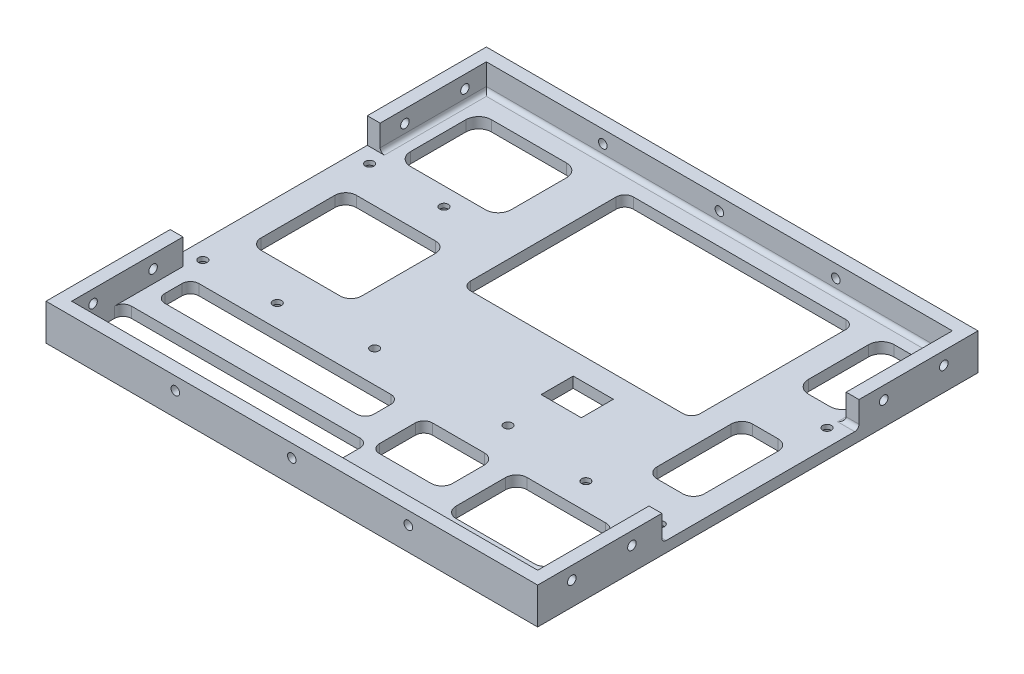
from build123d import *

# Parameters (mm, degrees)
SKETCH1_W           = 119
SKETCH1_H           = 103
BOSS_EXTRUDE1_DEPTH = 2.5
SKETCH3_W           = 55
SKETCH3_H           = 44
CUT_EXTRUDE2_DEPTH  = 10
SKETCH4_W           = 103
SKETCH4_H           = 2.5
BOSS_EXTRUDE2_DEPTH = 1.5
SKETCH5_W           = 103
SKETCH5_H           = 2.5
BOSS_EXTRUDE3_DEPTH = 1.5
SKETCH6_W           = 103
SKETCH6_H           = 2.5
CUT_EXTRUDE3_DEPTH  = 3.5
SKETCH7_W           = 103
SKETCH7_H           = 2.5
CUT_EXTRUDE4_DEPTH  = 3.5
SKETCH8_R           = 1
CUT_EXTRUDE5_DEPTH  = 10
CUT_EXTRUDE9_DEPTH  = 11
SKETCH13_W          = 7.420596405
SKETCH13_H          = 28.066266443
SKETCH13_H_2        = 28.109143465
BOSS_EXTRUDE4_DEPTH = 2.5
BOSS_EXTRUDE5_DEPTH = 5
FILLET1_R           = 1
SKETCH15_R          = 1
CUT_EXTRUDE10_DEPTH = 5
SKETCH16_R          = 1
CUT_EXTRUDE11_DEPTH = 5
BOSS_EXTRUDE6_DEPTH = 1
SKETCH18_R          = 1
CUT_EXTRUDE12_DEPTH = 10
SKETCH19_W          = 10.420596405
SKETCH19_H          = 31.066266443
SKETCH19_H_2        = 31.109143465
SKETCH19_W_2        = 9.39736678
SKETCH19_H_3        = 7.5
CUT_EXTRUDE13_DEPTH = 10
SKETCH20_R          = 2
CUT_EXTRUDE14_DEPTH = 1.5
SKETCH21_W          = 53.725269585
SKETCH21_H          = 38.08766447
CUT_EXTRUDE15_DEPTH = 21.5
FILLET2_R           = 2


with BuildPart() as part:
    # Sketch1 → Boss-Extrude1 (new body)
    with BuildSketch(Plane(origin=(0, 0, 0), x_dir=(1, 0, 0), z_dir=(0, 1, 0))):
        Rectangle(SKETCH1_W, SKETCH1_H)
    extrude(amount=BOSS_EXTRUDE1_DEPTH)

    # Sketch3 → Cut-Extrude2 (cut)
    with BuildSketch(Plane(origin=(0, 2.5, 0), x_dir=(1, 0, 0), z_dir=(0, 1, 0))):
        with Locations((9, 16.5)):
            Rectangle(SKETCH3_W, SKETCH3_H)
    extrude(amount=-CUT_EXTRUDE2_DEPTH, mode=Mode.SUBTRACT)

    # Sketch4 → Boss-Extrude2 (add)
    with BuildSketch(Plane.ZY.offset(59.5)):
        with Locations((0, 1.25)):
            Rectangle(SKETCH4_W, SKETCH4_H)
    extrude(amount=BOSS_EXTRUDE2_DEPTH)

    # Sketch5 → Boss-Extrude3 (add)
    with BuildSketch(Plane(origin=(59.5, 0, 0), x_dir=(0, 0, -1), z_dir=(1, 0, 0))):
        with Locations((0, 1.25)):
            Rectangle(SKETCH5_W, SKETCH5_H)
    extrude(amount=BOSS_EXTRUDE3_DEPTH)

    # Sketch6 → Cut-Extrude3 (cut)
    with BuildSketch(Plane.ZY.offset(61)):
        with Locations((0, 1.25)):
            Rectangle(SKETCH6_W, SKETCH6_H)
    extrude(amount=-CUT_EXTRUDE3_DEPTH, mode=Mode.SUBTRACT)

    # Sketch7 → Cut-Extrude4 (cut)
    with BuildSketch(Plane(origin=(61, 0, 0), x_dir=(0, 0, -1), z_dir=(1, 0, 0))):
        with Locations((0, 1.25)):
            Rectangle(SKETCH7_W, SKETCH7_H)
    extrude(amount=-CUT_EXTRUDE4_DEPTH, mode=Mode.SUBTRACT)

    # Sketch8 → Cut-Extrude5 (cut)
    with BuildSketch(Plane(origin=(0, 2.5, 0), x_dir=(1, 0, 0), z_dir=(0, 1, 0))):
        with Locations((-15.5, -44.96)):
            Circle(SKETCH8_R)
        with Locations((15.7, -44.96)):
            Circle(SKETCH8_R)
        with Locations((-15.5, -16.63)):
            Circle(SKETCH8_R)
        with Locations((15.7, -16.63)):
            Circle(SKETCH8_R)
        with Locations((-53.5, -18.81)):
            Circle(SKETCH8_R)
        with Locations((-36.1, -18.81)):
            Circle(SKETCH8_R)
        with Locations((-53.5, 20.19)):
            Circle(SKETCH8_R)
        with Locations((-36.1, 20.19)):
            Circle(SKETCH8_R)
        with Locations((36.1, -18.81)):
            Circle(SKETCH8_R)
        with Locations((53.5, -18.81)):
            Circle(SKETCH8_R)
        with Locations((53.5, 20.19)):
            Circle(SKETCH8_R)
    extrude(amount=-CUT_EXTRUDE5_DEPTH, mode=Mode.SUBTRACT)

    # Sketch12 → Cut-Extrude9 (cut)
    with BuildSketch(Plane(origin=(0, 2.5, 0), x_dir=(1, 0, 0), z_dir=(0, 1, 0))):
        with BuildLine():
            Line((18.457129996, -37.366758765), (6.341274381, -37.366758765))
            ThreePointArc((6.341274381, -37.366758765), (4.927060818, -36.780972327), (4.341274381, -35.366758765))
            Line((4.341274381, -35.366758765), (4.341274381, -26.945491093))
            ThreePointArc((4.341274381, -26.945491093), (4.927060818, -25.53127753), (6.341274381, -24.945491093))
            Line((6.341274381, -24.945491093), (18.457129996, -24.945491093))
            ThreePointArc((18.457129996, -24.945491093), (20.224896949, -25.67772414), (20.957129996, -27.445491093))
            Line((20.957129996, -27.445491093), (20.957129996, -34.866758765))
            ThreePointArc((20.957129996, -34.866758765), (20.224896949, -36.634525718), (18.457129996, -37.366758765))
        make_face()
        with BuildLine():
            Line((-48.675698452, -10.035902375), (-30.13630944, -10.035902375))
            ThreePointArc((-30.13630944, -10.035902375), (-28.368542487, -9.303669328), (-27.63630944, -7.535902375))
            Line((-27.63630944, -7.535902375), (-27.63630944, 9.759475357))
            ThreePointArc((-27.63630944, 9.759475357), (-28.368542487, 11.52724231), (-30.13630944, 12.259475357))
            Line((-30.13630944, 12.259475357), (-48.675698452, 12.259475357))
            ThreePointArc((-48.675698452, 12.259475357), (-50.443465405, 11.52724231), (-51.175698452, 9.759475357))
            Line((-51.175698452, 9.759475357), (-51.175698452, -7.535902375))
            ThreePointArc((-51.175698452, -7.535902375), (-50.443465405, -9.303669328), (-48.675698452, -10.035902375))
        make_face()
        with BuildLine():
            Line((0.941406426, -48.5), (-52.5, -48.5))
            ThreePointArc((-52.5, -48.5), (-53.914213562, -47.914213562), (-54.5, -46.5))
            Line((-54.5, -46.5), (-54.5, -38.5))
            ThreePointArc((-54.5, -38.5), (-53.914213562, -37.085786438), (-52.5, -36.5))
            Line((-52.5, -36.5), (0.941406426, -36.5))
            ThreePointArc((0.941406426, -36.5), (2.355619989, -37.085786438), (2.941406426, -38.5))
            Line((2.941406426, -38.5), (2.941406426, -46.5))
            ThreePointArc((2.941406426, -46.5), (2.355619989, -47.914213562), (0.941406426, -48.5))
        make_face()
        with BuildLine():
            Line((28.457129996, -41.565269049), (46.850265705, -41.565269049))
            ThreePointArc((46.850265705, -41.565269049), (48.618032658, -40.833036002), (49.350265705, -39.065269049))
            Line((49.350265705, -39.065269049), (49.350265705, -27.445491093))
            ThreePointArc((49.350265705, -27.445491093), (48.618032658, -25.67772414), (46.850265705, -24.945491093))
            Line((46.850265705, -24.945491093), (28.457129996, -24.945491093))
            ThreePointArc((28.457129996, -24.945491093), (26.689363043, -25.67772414), (25.957129996, -27.445491093))
            Line((25.957129996, -27.445491093), (25.957129996, -39.065269049))
            ThreePointArc((25.957129996, -39.065269049), (26.689363043, -40.833036002), (28.457129996, -41.565269049))
        make_face()
        with BuildLine():
            Line((41.5, 9.759475357), (41.5, -7.535902375))
            ThreePointArc((41.5, -7.535902375), (42.232233047, -9.303669328), (44, -10.035902375))
            Line((44, -10.035902375), (50, -10.035902375))
            ThreePointArc((50, -10.035902375), (51.767766953, -9.303669328), (52.5, -7.535902375))
            Line((52.5, -7.535902375), (52.5, 9.759475357))
            ThreePointArc((52.5, 9.759475357), (51.767766953, 11.52724231), (50, 12.259475357))
            Line((50, 12.259475357), (44, 12.259475357))
            ThreePointArc((44, 12.259475357), (42.232233047, 11.52724231), (41.5, 9.759475357))
        make_face()
        with BuildLine():
            Line((-4.277537088, -32.033396205), (-49.175698452, -32.033396205))
            ThreePointArc((-49.175698452, -32.033396205), (-50.589912015, -31.447609768), (-51.175698452, -30.033396205))
            Line((-51.175698452, -30.033396205), (-51.175698452, -26.033396205))
            ThreePointArc((-51.175698452, -26.033396205), (-50.589912015, -24.619182643), (-49.175698452, -24.033396205))
            Line((-49.175698452, -24.033396205), (-4.277537088, -24.033396205))
            ThreePointArc((-4.277537088, -24.033396205), (-2.863323525, -24.619182643), (-2.277537088, -26.033396205))
            Line((-2.277537088, -26.033396205), (-2.277537088, -30.033396205))
            ThreePointArc((-2.277537088, -30.033396205), (-2.863323525, -31.447609768), (-4.277537088, -32.033396205))
        make_face()
        with BuildLine():
            Line((-30.63630944, 24.426024877), (-48.175698452, 24.426024877))
            ThreePointArc((-48.175698452, 24.426024877), (-50.297018796, 25.304704534), (-51.175698452, 27.426024877))
            Line((-51.175698452, 27.426024877), (-51.175698452, 40.3778965))
            ThreePointArc((-51.175698452, 40.3778965), (-50.297018796, 42.499216844), (-48.175698452, 43.3778965))
            Line((-48.175698452, 43.3778965), (-30.63630944, 43.3778965))
            ThreePointArc((-30.63630944, 43.3778965), (-28.514989096, 42.499216844), (-27.63630944, 40.3778965))
            Line((-27.63630944, 40.3778965), (-27.63630944, 27.426024877))
            ThreePointArc((-27.63630944, 27.426024877), (-28.514989096, 25.304704534), (-30.63630944, 24.426024877))
        make_face()
        with BuildLine():
            Line((49.5, 24.845275514), (44.5, 24.845275514))
            ThreePointArc((44.5, 24.845275514), (42.378679656, 25.72395517), (41.5, 27.845275514))
            Line((41.5, 27.845275514), (41.5, 41.894735662))
            ThreePointArc((41.5, 41.894735662), (42.378679656, 44.016056005), (44.5, 44.894735662))
            Line((44.5, 44.894735662), (49.5, 44.894735662))
            ThreePointArc((49.5, 44.894735662), (51.621320344, 44.016056005), (52.5, 41.894735662))
            Line((52.5, 41.894735662), (52.5, 27.845275514))
            ThreePointArc((52.5, 27.845275514), (51.621320344, 25.72395517), (49.5, 24.845275514))
        make_face()
    extrude(amount=-CUT_EXTRUDE9_DEPTH, mode=Mode.SUBTRACT)

    # Sketch13 → Boss-Extrude4 (add)
    with BuildSketch(Plane(origin=(0, 2.5, 0), x_dir=(1, 0, 0), z_dir=(0, 1, 0))):
        Polygon((21.712749583, -5.5), (36.5, -5.5), (36.5, 7.734017607), (36.5, 38.5), (26.428134907, 38.5), (-8.428134907, 38.5), (-18.5, 38.5), (-18.5, 7.734017607), (-18.5, -5.5), (-3.712749583, -5.5), (3.684617197, -5.5), (14.315382803, -5.5), (14.315382803, -0.063611644), (21.712749583, -0.063611644), align=None)
        with Locations((30.567238931, 21.767150829)):
            Rectangle(SKETCH13_W, SKETCH13_H, mode=Mode.SUBTRACT)
        with Locations((-12.567238931, 21.788589339)):
            Rectangle(SKETCH13_W, SKETCH13_H_2, mode=Mode.SUBTRACT)
    extrude(amount=-BOSS_EXTRUDE4_DEPTH)

    # Sketch14 → Boss-Extrude5 (add)
    with BuildSketch(Plane(origin=(0, 2.5, 0), x_dir=(1, 0, 0), z_dir=(0, 1, 0))):
        Polygon((57.5, 23.659080622), (54.5, 23.659080622), (54.5, 48.5), (-54.5, 48.5), (-54.5, 23.659080622), (-57.5, 23.659080622), (-57.5, 51.5), (57.5, 51.5), align=None)
        Polygon((57.5, -22.451645152), (54.5, -22.451645152), (54.5, -48.5), (-54.5, -48.5), (-54.5, -22.451645152), (-57.5, -22.451645152), (-57.5, -51.5), (57.5, -51.5), align=None)
    extrude(amount=BOSS_EXTRUDE5_DEPTH)

    # Fillet1
    fillet1_edges = [part.edges().sort_by_distance(p)[0] for p in [
        (-54.5, 2.5, -36.079540311),
        (0, 2.5, -48.5),
        (54.5, 2.5, -36.079540311),
        (56, 2.5, -23.659080622),
        (56, 2.5, 22.451645152),
        (54.5, 2.5, 35.475822576),
        (27.720703213, 2.5, 48.5),
        (-54.5, 2.5, 47.5),
    ]]
    fillet(fillet1_edges, radius=FILLET1_R)

    # Sketch15 → Cut-Extrude10 (cut)
    with BuildSketch(Plane.ZY.offset(-54.5)):
        with Locations((29.451645152, 5.5)):
            Circle(SKETCH15_R)
        with Locations((43.5, 5.5)):
            Circle(SKETCH15_R)
    cut_extrude10 = extrude(amount=-CUT_EXTRUDE10_DEPTH, mode=Mode.SUBTRACT)

    # Sketch16 → Cut-Extrude11 (cut)
    with BuildSketch(Plane(origin=(0, 0, 48.5), x_dir=(-1, 0, 0), z_dir=(0, 0, -1))):
        with Locations((0, 5.5)):
            Circle(SKETCH16_R)
        with Locations((-27.25, 5.5)):
            Circle(SKETCH16_R)
        with Locations((27.25, 5.5)):
            Circle(SKETCH16_R)
    cut_extrude11 = extrude(amount=-CUT_EXTRUDE11_DEPTH, mode=Mode.SUBTRACT)

    # Sketch17 → Boss-Extrude6 (add)
    with BuildSketch(Plane(origin=(0, 7.5, 0), x_dir=(1, 0, 0), z_dir=(0, 1, 0))):
        Polygon((57.5, -51.5), (57.5, -22.451645152), (54.5, -22.451645152), (54.5, -48.5), (-54.5, -48.5), (-54.5, -22.451645152), (-57.5, -22.451645152), (-57.5, -51.5), align=None)
        Polygon((57.5, 23.659080622), (57.5, 51.5), (-57.5, 51.5), (-57.5, 23.659080622), (-54.5, 23.659080622), (-54.5, 48.5), (54.5, 48.5), (54.5, 23.659080622), align=None)
    extrude(amount=BOSS_EXTRUDE6_DEPTH)

    # Mirror1: Cut-Extrude10, Cut-Extrude11 across plane
    add(cut_extrude10.mirror(Plane.XY), mode=Mode.SUBTRACT)
    add(cut_extrude11.mirror(Plane.XY), mode=Mode.SUBTRACT)

    # Mirror2: Cut-Extrude10 across plane
    add(cut_extrude10.mirror(Plane(origin=(0, 0, 0), x_dir=(0, 0, 1), z_dir=(1, 0, 0))), mode=Mode.SUBTRACT)

    # Sketch18 → Cut-Extrude12 (cut)
    with BuildSketch(Plane(origin=(-54.5, 0, 0), x_dir=(0, 0, -1), z_dir=(1, 0, 0))):
        with Locations((43.5, 5.5)):
            Circle(SKETCH18_R)
        with Locations((29.451645152, 5.5)):
            Circle(SKETCH18_R)
    extrude(amount=-CUT_EXTRUDE12_DEPTH, mode=Mode.SUBTRACT)

    # Sketch19 → Cut-Extrude13 (cut)
    with BuildSketch(Plane(origin=(0, 2.5, 0), x_dir=(1, 0, 0), z_dir=(0, 1, 0))):
        with Locations((30.567238931, 21.767150829)):
            Rectangle(SKETCH19_W, SKETCH19_H)
        with Locations((-12.567238931, 21.788589339)):
            Rectangle(SKETCH19_W, SKETCH19_H_2)
        with Locations((18.014066193, -2.75)):
            Rectangle(SKETCH19_W_2, SKETCH19_H_3)
    extrude(amount=-CUT_EXTRUDE13_DEPTH, mode=Mode.SUBTRACT)

    # Sketch20 → Cut-Extrude14 (cut)
    with BuildSketch(Plane.XZ):
        with Locations((-53.5, 18.81)):
            Circle(SKETCH20_R)
        with Locations((-36.1, 18.81)):
            Circle(SKETCH20_R)
        with Locations((-53.5, -20.19)):
            Circle(SKETCH20_R)
        with Locations((-36.1, -20.19)):
            Circle(SKETCH20_R)
        with Locations((53.5, 18.81)):
            Circle(SKETCH20_R)
        with Locations((36.1, 18.81)):
            Circle(SKETCH20_R)
        with Locations((53.5, -20.19)):
            Circle(SKETCH20_R)
    extrude(amount=-CUT_EXTRUDE14_DEPTH, mode=Mode.SUBTRACT)

    # Sketch21 → Cut-Extrude15 (cut)
    with BuildSketch(Plane(origin=(0, 2.5, 0), x_dir=(1, 0, 0), z_dir=(0, 1, 0))):
        with Locations((8.914902341, 25.277849842)):
            Rectangle(SKETCH21_W, SKETCH21_H)
    extrude(amount=-CUT_EXTRUDE15_DEPTH, mode=Mode.SUBTRACT)

    # Fillet2
    fillet2_edges = [part.edges().sort_by_distance(p)[0] for p in [
        (35.777537133, 1.25, -6.234017607),
        (35.777537133, 1.25, -44.321682077),
        (-17.947732452, 1.25, -6.234017607),
        (-17.947732452, 1.25, -44.321682077),
    ]]
    fillet(fillet2_edges, radius=FILLET2_R)


solid = part.part
